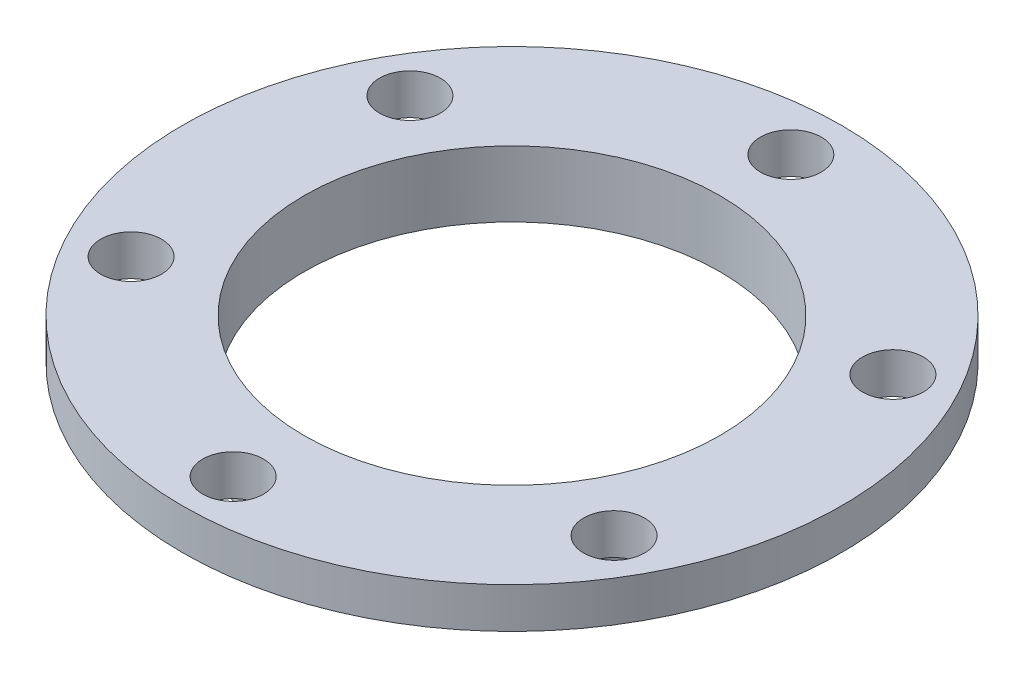
from build123d import *

# Parameters (mm, degrees)
SKETCH1_R               = 32.5
SKETCH1_R_2             = 20.5
BOSS_EXTRUDE1_DEPTH     = 4
SKETCH2_R               = 23.5
SKETCH2_R_2             = 20.5
BOSS_EXTRUDE2_DEPTH     = 2.5
SKETCH3_R               = 3
CUT_EXTRUDE1_DEPTH      = 1
CUT_EXTRUDE1_DEPTH_BACK = 7.5


with BuildPart() as part:
    # Sketch1 → Boss-Extrude1 (new body)
    with BuildSketch(Plane(origin=(0, 0, 0), x_dir=(1, 0, 0), z_dir=(0, 1, 0))):
        Circle(SKETCH1_R)
        Circle(SKETCH1_R_2, mode=Mode.SUBTRACT)
    extrude(amount=BOSS_EXTRUDE1_DEPTH)

    # Sketch2 → Boss-Extrude2 (add)
    with BuildSketch(Plane.XZ):
        Circle(SKETCH2_R)
        Circle(SKETCH2_R_2, mode=Mode.SUBTRACT)
    extrude(amount=BOSS_EXTRUDE2_DEPTH)

    # Sketch3 → Cut-Extrude1 (cut, two sides)
    with BuildSketch(Plane(origin=(0, 4, 0), x_dir=(1, 0, 0), z_dir=(0, 1, 0))) as cut_extrude1_sk:
        with Locations((0, 27.5)):
            Circle(SKETCH3_R)
        with Locations((23.815698604, 13.75)):
            Circle(SKETCH3_R)
        with Locations((23.815698604, -13.75)):
            Circle(SKETCH3_R)
        with Locations((0, -27.5)):
            Circle(SKETCH3_R)
        with Locations((-23.815698604, -13.75)):
            Circle(SKETCH3_R)
        with Locations((-23.815698604, 13.75)):
            Circle(SKETCH3_R)
    extrude(amount=CUT_EXTRUDE1_DEPTH, mode=Mode.SUBTRACT)
    extrude(cut_extrude1_sk.sketch, amount=-CUT_EXTRUDE1_DEPTH_BACK, mode=Mode.SUBTRACT)


solid = part.part
